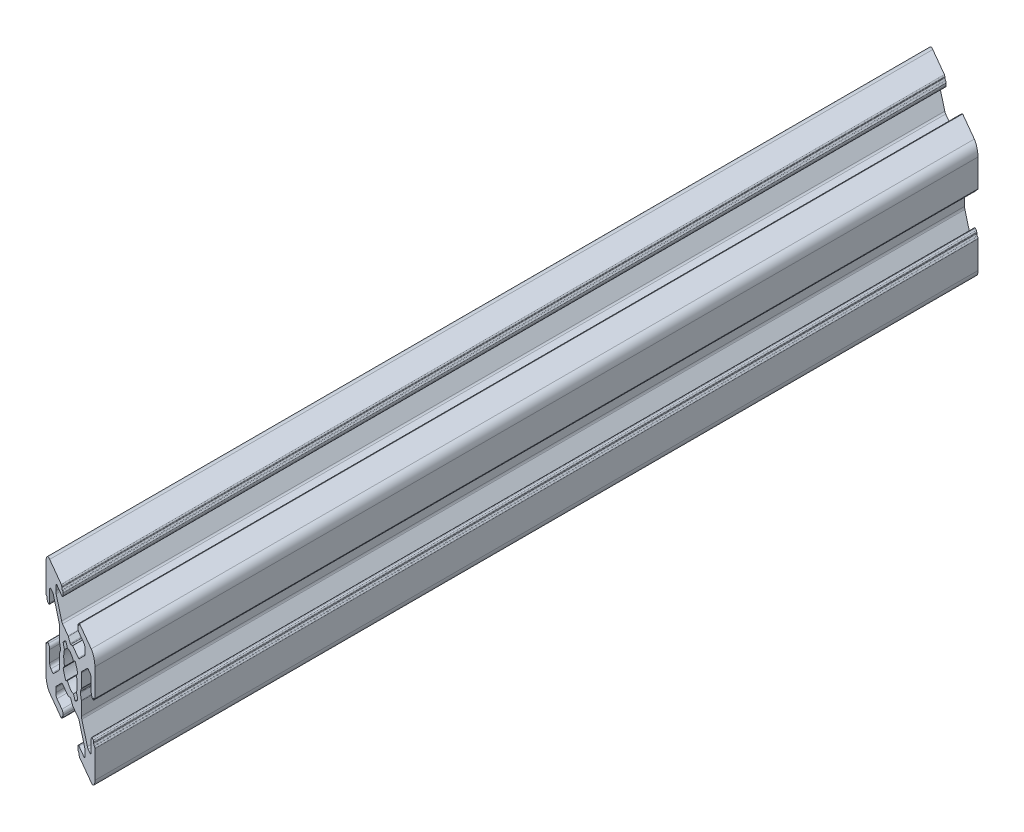
from build123d import *

# Parameters (mm, degrees)
EXTRUDE1_DEPTH          = 200
CUT_EXTRUDE1_DEPTH      = 11
CUT_EXTRUDE1_DEPTH_BACK = 11


with BuildPart() as part:
    # Sketch1 → Extrude1 (new body)
    with BuildSketch(Plane.XY):
        with BuildLine():
            Line((-3.5, 8.499999673), (-5.500000686, 8.499999673))
            ThreePointArc((-5.500000686, 8.499999673), (-5.853554077, 8.353553064), (-6.000000686, 7.999999673))
            Line((-6.000000686, 7.999999673), (-6.000000686, 7.267766626))
            ThreePointArc((-6.000000686, 7.267766626), (-5.961940448, 7.076424899), (-5.853554059, 6.914213219))
            Line((-5.853554059, 6.914213219), (-3.585787212, 4.646446592))
            ThreePointArc((-3.585787212, 4.646446592), (-3.423575544, 4.538060229), (-3.232233839, 4.5))
            Line((-3.232233839, 4.5), (-0.953590312, 4.5))
            ThreePointArc((-0.953590312, 4.5), (-0.901826505, 4.493185166), (-0.853590316, 4.473205083))
            Line((-0.853590316, 4.473205083), (-0.100000045, 4.038119562))
            ThreePointArc((-0.100000045, 4.038119562), (0, 4.011324632), (0.100000045, 4.038119562))
            Line((0.100000045, 4.038119562), (0.853590316, 4.473205083))
            ThreePointArc((0.853590316, 4.473205083), (0.901826505, 4.493185166), (0.953590312, 4.5))
            Line((0.953590312, 4.5), (3.232233839, 4.5))
            ThreePointArc((3.232233839, 4.5), (3.423575544, 4.538060229), (3.585787212, 4.646446592))
            Line((3.585787212, 4.646446592), (5.853554059, 6.914213219))
            ThreePointArc((5.853554059, 6.914213219), (5.961940448, 7.076424899), (6.000000686, 7.267766626))
            Line((6.000000686, 7.267766626), (6.000000686, 7.999999673))
            ThreePointArc((6.000000686, 7.999999673), (5.853554077, 8.353553064), (5.500000686, 8.499999673))
            Line((5.500000686, 8.499999673), (3.5, 8.499999673))
            ThreePointArc((3.5, 8.499999673), (3.146446609, 8.646446283), (3, 8.999999673))
            Line((3, 8.999999673), (3, 9.3))
            ThreePointArc((3, 9.3), (3.058578644, 9.441421356), (3.2, 9.5))
            Line((3.2, 9.5), (3.350000228, 9.5))
            ThreePointArc((3.350000228, 9.5), (3.491421584, 9.558578644), (3.550000228, 9.7))
            Line((3.550000228, 9.7), (3.550000228, 9.8))
            ThreePointArc((3.550000228, 9.8), (3.608578871, 9.941421356), (3.750000228, 10))
            Line((3.750000228, 10), (8.5, 10))
            ThreePointArc((8.5, 10), (9.560660172, 9.560660172), (10, 8.5))
            Line((10, 8.5), (10, 3.749999605))
            ThreePointArc((10, 3.749999605), (9.941421356, 3.608578248), (9.8, 3.549999605))
            Line((9.8, 3.549999605), (9.699999732, 3.549999605))
            ThreePointArc((9.699999732, 3.549999605), (9.558578376, 3.491420961), (9.499999732, 3.349999605))
            Line((9.499999732, 3.349999605), (9.499999732, 3.2))
            ThreePointArc((9.499999732, 3.2), (9.441421088, 3.058578644), (9.299999732, 3))
            Line((9.299999732, 3), (8.999999732, 3))
            ThreePointArc((8.999999732, 3), (8.646446341, 3.146446609), (8.499999732, 3.5))
            Line((8.499999732, 3.5), (8.499999732, 5.499999605))
            ThreePointArc((8.499999732, 5.499999605), (8.353553123, 5.853552995), (7.999999732, 5.999999605))
            Line((7.999999732, 5.999999605), (7.267766685, 5.999999605))
            ThreePointArc((7.267766685, 5.999999605), (7.076424969, 5.961939371), (6.914213294, 5.853552995))
            Line((6.914213294, 5.853552995), (4.646446398, 3.585786099))
            ThreePointArc((4.646446398, 3.585786099), (4.538060023, 3.423574425), (4.499999789, 3.232232708))
            Line((4.499999789, 3.232232708), (4.499999789, 0.953589302))
            ThreePointArc((4.499999789, 0.953589302), (4.493184953, 0.90182549), (4.473204867, 0.853589297))
            Line((4.473204867, 0.853589297), (4.038119841, 0.099999969))
            ThreePointArc((4.038119841, 0.099999969), (4.011324929, 0), (4.038119841, -0.099999969))
            Line((4.038119841, -0.099999969), (4.473204867, -0.853589297))
            ThreePointArc((4.473204867, -0.853589297), (4.493184953, -0.90182549), (4.499999789, -0.953589302))
            Line((4.499999789, -0.953589302), (4.499999789, -3.232232708))
            ThreePointArc((4.499999789, -3.232232708), (4.538060023, -3.423574425), (4.646446398, -3.585786099))
            Line((4.646446398, -3.585786099), (6.914213294, -5.853552995))
            ThreePointArc((6.914213294, -5.853552995), (7.076424969, -5.961939371), (7.267766685, -5.999999605))
            Line((7.267766685, -5.999999605), (7.999999732, -5.999999605))
            ThreePointArc((7.999999732, -5.999999605), (8.353553123, -5.853552995), (8.499999732, -5.499999605))
            Line((8.499999732, -5.499999605), (8.499999732, -3.5))
            ThreePointArc((8.499999732, -3.5), (8.646446341, -3.146446609), (8.999999732, -3))
            Line((8.999999732, -3), (9.299999732, -3))
            ThreePointArc((9.299999732, -3), (9.441421088, -3.058578644), (9.499999732, -3.2))
            Line((9.499999732, -3.2), (9.499999732, -3.349999605))
            ThreePointArc((9.499999732, -3.349999605), (9.558578376, -3.491420961), (9.699999732, -3.549999605))
            Line((9.699999732, -3.549999605), (9.8, -3.549999605))
            ThreePointArc((9.8, -3.549999605), (9.941421356, -3.608578248), (10, -3.749999605))
            Line((10, -3.749999605), (10, -8.5))
            ThreePointArc((10, -8.5), (9.560660172, -9.560660172), (8.5, -10))
            Line((8.5, -10), (3.750000228, -10))
            ThreePointArc((3.750000228, -10), (3.608578871, -9.941421356), (3.550000228, -9.8))
            Line((3.550000228, -9.8), (3.550000228, -9.7))
            ThreePointArc((3.550000228, -9.7), (3.491421584, -9.558578644), (3.350000228, -9.5))
            Line((3.350000228, -9.5), (3.2, -9.5))
            ThreePointArc((3.2, -9.5), (3.058578644, -9.441421356), (3, -9.3))
            Line((3, -9.3), (3, -8.999999673))
            ThreePointArc((3, -8.999999673), (3.146446609, -8.646446283), (3.5, -8.499999673))
            Line((3.5, -8.499999673), (5.500000686, -8.499999673))
            ThreePointArc((5.500000686, -8.499999673), (5.853554077, -8.353553064), (6.000000686, -7.999999673))
            Line((6.000000686, -7.999999673), (6.000000686, -7.267766626))
            ThreePointArc((6.000000686, -7.267766626), (5.961940448, -7.076424899), (5.853554059, -6.914213219))
            Line((5.853554059, -6.914213219), (3.585787212, -4.646446592))
            ThreePointArc((3.585787212, -4.646446592), (3.423575544, -4.538060229), (3.232233839, -4.5))
            Line((3.232233839, -4.5), (0.953590312, -4.5))
            ThreePointArc((0.953590312, -4.5), (0.901826505, -4.493185166), (0.853590316, -4.473205083))
            Line((0.853590316, -4.473205083), (0.100000045, -4.038119562))
            ThreePointArc((0.100000045, -4.038119562), (0, -4.011324632), (-0.100000045, -4.038119562))
            Line((-0.100000045, -4.038119562), (-0.853590316, -4.473205083))
            ThreePointArc((-0.853590316, -4.473205083), (-0.901826505, -4.493185166), (-0.953590312, -4.5))
            Line((-0.953590312, -4.5), (-3.232233839, -4.5))
            ThreePointArc((-3.232233839, -4.5), (-3.423575544, -4.538060229), (-3.585787212, -4.646446592))
            Line((-3.585787212, -4.646446592), (-5.853554059, -6.914213219))
            ThreePointArc((-5.853554059, -6.914213219), (-5.961940448, -7.076424899), (-6.000000686, -7.267766626))
            Line((-6.000000686, -7.267766626), (-6.000000686, -7.999999673))
            ThreePointArc((-6.000000686, -7.999999673), (-5.853554077, -8.353553064), (-5.500000686, -8.499999673))
            Line((-5.500000686, -8.499999673), (-3.5, -8.499999673))
            ThreePointArc((-3.5, -8.499999673), (-3.146446609, -8.646446283), (-3, -8.999999673))
            Line((-3, -8.999999673), (-3, -9.3))
            ThreePointArc((-3, -9.3), (-3.058578644, -9.441421356), (-3.2, -9.5))
            Line((-3.2, -9.5), (-3.350000228, -9.5))
            ThreePointArc((-3.350000228, -9.5), (-3.491421584, -9.558578644), (-3.550000228, -9.7))
            Line((-3.550000228, -9.7), (-3.550000228, -9.8))
            ThreePointArc((-3.550000228, -9.8), (-3.608578871, -9.941421356), (-3.750000228, -10))
            Line((-3.750000228, -10), (-8.5, -10))
            ThreePointArc((-8.5, -10), (-9.560660172, -9.560660172), (-10, -8.5))
            Line((-10, -8.5), (-10, -3.749999605))
            ThreePointArc((-10, -3.749999605), (-9.941421356, -3.608578248), (-9.8, -3.549999605))
            Line((-9.8, -3.549999605), (-9.699999732, -3.549999605))
            ThreePointArc((-9.699999732, -3.549999605), (-9.558578376, -3.491420961), (-9.499999732, -3.349999605))
            Line((-9.499999732, -3.349999605), (-9.499999732, -3.2))
            ThreePointArc((-9.499999732, -3.2), (-9.441421088, -3.058578644), (-9.299999732, -3))
            Line((-9.299999732, -3), (-8.999999732, -3))
            ThreePointArc((-8.999999732, -3), (-8.646446341, -3.146446609), (-8.499999732, -3.5))
            Line((-8.499999732, -3.5), (-8.499999732, -5.499999605))
            ThreePointArc((-8.499999732, -5.499999605), (-8.353553123, -5.853552995), (-7.999999732, -5.999999605))
            Line((-7.999999732, -5.999999605), (-7.267766685, -5.999999605))
            ThreePointArc((-7.267766685, -5.999999605), (-7.076424969, -5.961939371), (-6.914213294, -5.853552995))
            Line((-6.914213294, -5.853552995), (-4.646446398, -3.585786099))
            ThreePointArc((-4.646446398, -3.585786099), (-4.538060023, -3.423574425), (-4.499999789, -3.232232708))
            Line((-4.499999789, -3.232232708), (-4.499999789, -0.953589302))
            ThreePointArc((-4.499999789, -0.953589302), (-4.493184953, -0.90182549), (-4.473204867, -0.853589297))
            Line((-4.473204867, -0.853589297), (-4.038119841, -0.099999969))
            ThreePointArc((-4.038119841, -0.099999969), (-4.011324929, 0), (-4.038119841, 0.099999969))
            Line((-4.038119841, 0.099999969), (-4.473204867, 0.853589297))
            ThreePointArc((-4.473204867, 0.853589297), (-4.493184953, 0.90182549), (-4.499999789, 0.953589302))
            Line((-4.499999789, 0.953589302), (-4.499999789, 3.232232708))
            ThreePointArc((-4.499999789, 3.232232708), (-4.538060023, 3.423574425), (-4.646446398, 3.585786099))
            Line((-4.646446398, 3.585786099), (-6.914213294, 5.853552995))
            ThreePointArc((-6.914213294, 5.853552995), (-7.076424969, 5.961939371), (-7.267766685, 5.999999605))
            Line((-7.267766685, 5.999999605), (-7.999999732, 5.999999605))
            ThreePointArc((-7.999999732, 5.999999605), (-8.353553123, 5.853552995), (-8.499999732, 5.499999605))
            Line((-8.499999732, 5.499999605), (-8.499999732, 3.5))
            ThreePointArc((-8.499999732, 3.5), (-8.646446341, 3.146446609), (-8.999999732, 3))
            Line((-8.999999732, 3), (-9.299999732, 3))
            ThreePointArc((-9.299999732, 3), (-9.441421088, 3.058578644), (-9.499999732, 3.2))
            Line((-9.499999732, 3.2), (-9.499999732, 3.349999605))
            ThreePointArc((-9.499999732, 3.349999605), (-9.558578376, 3.491420961), (-9.699999732, 3.549999605))
            Line((-9.699999732, 3.549999605), (-9.8, 3.549999605))
            ThreePointArc((-9.8, 3.549999605), (-9.941421356, 3.608578248), (-10, 3.749999605))
            Line((-10, 3.749999605), (-10, 8.5))
            ThreePointArc((-10, 8.5), (-9.560660172, 9.560660172), (-8.5, 10))
            Line((-8.5, 10), (-3.750000228, 10))
            ThreePointArc((-3.750000228, 10), (-3.608578871, 9.941421356), (-3.550000228, 9.8))
            Line((-3.550000228, 9.8), (-3.550000228, 9.7))
            ThreePointArc((-3.550000228, 9.7), (-3.491421584, 9.558578644), (-3.350000228, 9.5))
            Line((-3.350000228, 9.5), (-3.2, 9.5))
            ThreePointArc((-3.2, 9.5), (-3.058578644, 9.441421356), (-3, 9.3))
            Line((-3, 9.3), (-3, 8.999999673))
            ThreePointArc((-3, 8.999999673), (-3.146446609, 8.646446283), (-3.5, 8.499999673))
        make_face()
        with BuildLine():
            Line((-1.258185436, 2.445295362), (-1.91389502, 2.989640962))
            ThreePointArc((-1.91389502, 2.989640962), (-2.511737261, 2.508410485), (-2.992174953, 1.909930962))
            Line((-2.992174953, 1.909930962), (-2.445295423, 1.258185317))
            ThreePointArc((-2.445295423, 1.258185317), (-2.75, 0), (-2.445295423, -1.258185317))
            Line((-2.445295423, -1.258185317), (-2.992174953, -1.909930962))
            ThreePointArc((-2.992174953, -1.909930962), (-2.511737261, -2.508410485), (-1.91389502, -2.989640962))
            Line((-1.91389502, -2.989640962), (-1.258185436, -2.445295362))
            ThreePointArc((-1.258185436, -2.445295362), (0, -2.75), (1.258185436, -2.445295362))
            Line((1.258185436, -2.445295362), (1.91389502, -2.989640962))
            ThreePointArc((1.91389502, -2.989640962), (2.511737261, -2.508410485), (2.992174953, -1.909930962))
            Line((2.992174953, -1.909930962), (2.445295423, -1.258185317))
            ThreePointArc((2.445295423, -1.258185317), (2.75, 0), (2.445295423, 1.258185317))
            Line((2.445295423, 1.258185317), (2.992174953, 1.909930962))
            ThreePointArc((2.992174953, 1.909930962), (2.511737261, 2.508410485), (1.91389502, 2.989640962))
            Line((1.91389502, 2.989640962), (1.258185436, 2.445295362))
            ThreePointArc((1.258185436, 2.445295362), (0, 2.75), (-1.258185436, 2.445295362))
        make_face(mode=Mode.SUBTRACT)
    extrude(amount=EXTRUDE1_DEPTH)

    # Sketch2 → Cut-Extrude1 (cut, two sides)
    with BuildSketch(Plane(origin=(0, 0, 0), x_dir=(1, 0, 0), z_dir=(0, 1, 0))) as cut_extrude1_sk:
        Polygon((10, -29.433502692), (-10, -17.886497308), (-10, 13.956953757), (10, 13.956953757), align=None)
        Polygon((-10, -170.566497308), (10, -182.113502692), (10, -215.543691948), (-10, -215.543691948), align=None)
    extrude(amount=CUT_EXTRUDE1_DEPTH, mode=Mode.SUBTRACT)
    extrude(cut_extrude1_sk.sketch, amount=-CUT_EXTRUDE1_DEPTH_BACK, mode=Mode.SUBTRACT)


solid = part.part
